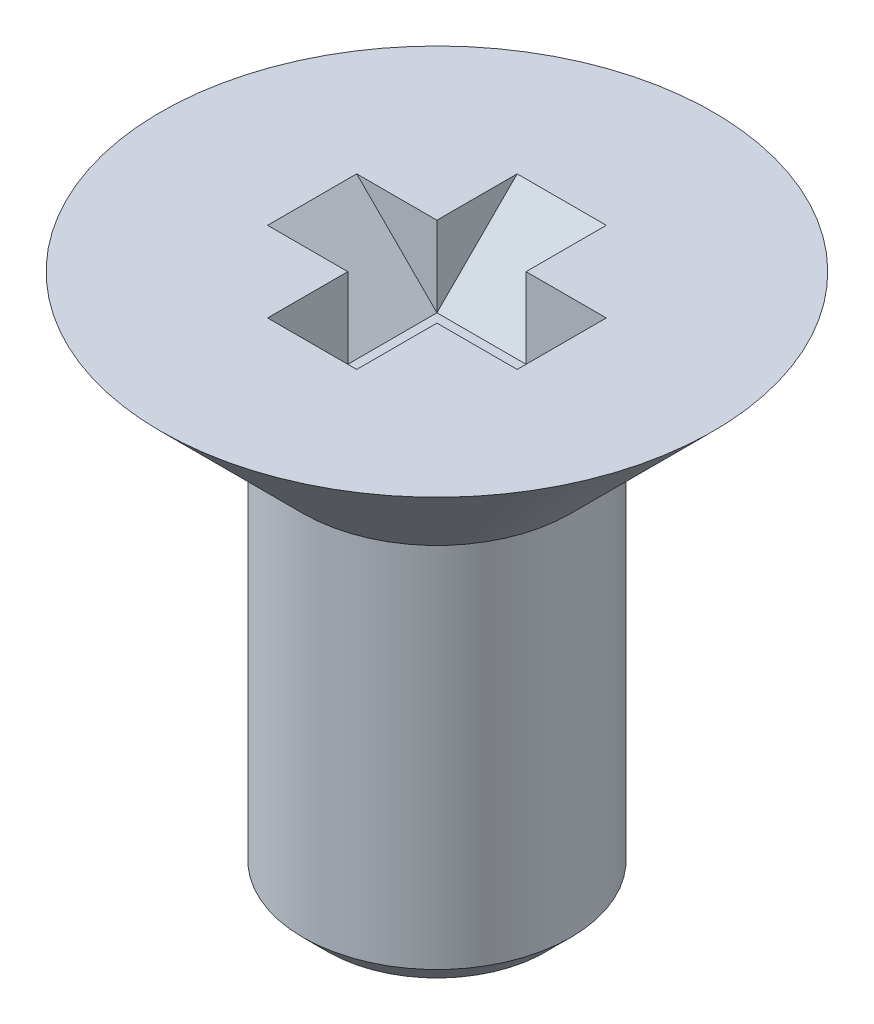
from build123d import *

# Parameters (mm, degrees)
CHAMFER_1_SIZE           = 0.2805
CUT_EXTRUDE_1_DEPTH      = 0.5
PATTERN_CIRCULAR_1_COUNT = 4
SKETCH_3_W               = 1
SKETCH_3_H               = 1
EXTRUDE_1_DEPTH          = 2


with BuildPart() as part:
    # Sketch 1 → Revolve 1 (revolve)
    with BuildSketch(Plane.XY):
        Polygon((0, 0), (3.1, 0), (1.5, -1.6), (1.5, -6), (0, -6), align=None)
    revolve(axis=Axis((0, 0, 0), (0, -1, 0)))

    # Chamfer 1
    chamfer_1_edges = [part.edges().sort_by_distance(p)[0] for p in [
        (-1.5, -6, 0),
    ]]
    chamfer(chamfer_1_edges, length=CHAMFER_1_SIZE)

    # Sketch 2 → Cut-Extrude 1 (cut, symmetric)
    with BuildSketch(Plane.XY):
        Polygon((0, 0), (0, -1.4), (-1.4, 0), align=None)
    cut_extrude_1 = extrude(amount=CUT_EXTRUDE_1_DEPTH, both=True, mode=Mode.SUBTRACT)

    # Pattern Circular 1: Cut-Extrude 1 ×4 about axis
    pattern_circular_1_axis = Axis((0, 0, 0), (0, 1, 0))
    for i in range(1, PATTERN_CIRCULAR_1_COUNT):
        add(cut_extrude_1.rotate(pattern_circular_1_axis, i * 360 / PATTERN_CIRCULAR_1_COUNT), mode=Mode.SUBTRACT)

    # Sketch 3 → Extrude 1 (add)
    with BuildSketch(Plane(origin=(0, -0.9, 0), x_dir=(1, 0, 0), z_dir=(0, 1, 0))):
        Rectangle(SKETCH_3_W, SKETCH_3_H)
    extrude(amount=-EXTRUDE_1_DEPTH)


solid = part.part
